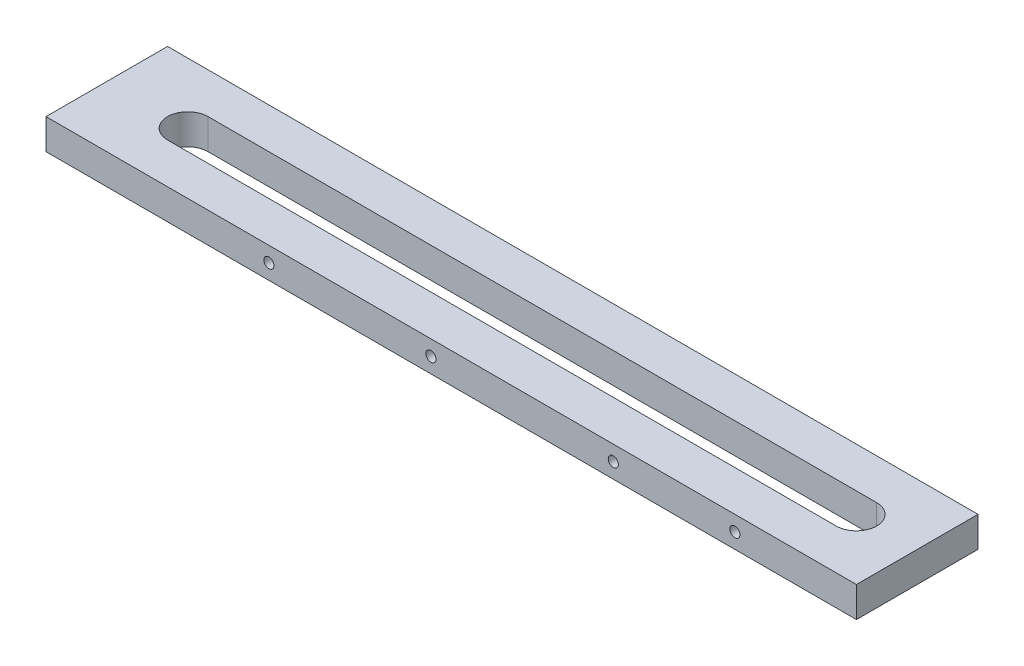
from build123d import *

# Parameters (mm, degrees)
SKETCH1_W           = 508
SKETCH1_H           = 76.2
BOSS_EXTRUDE1_DEPTH = 19.05
CUT_EXTRUDE1_DEPTH  = 20.05
SKETCH5_R           = 3.175
CUT_EXTRUDE3_DEPTH  = 12.7


with BuildPart() as part:
    # Sketch1 → Boss-Extrude1 (new body)
    with BuildSketch(Plane(origin=(0, 0, 0), x_dir=(1, 0, 0), z_dir=(0, 1, 0))):
        Rectangle(SKETCH1_W, SKETCH1_H)
    extrude(amount=BOSS_EXTRUDE1_DEPTH)

    # Sketch3 → Cut-Extrude1 (cut, through all)
    with BuildSketch(Plane(origin=(0, 19.05, 0), x_dir=(1, 0, 0), z_dir=(0, 1, 0))):
        with BuildLine():
            Line((-203.2, 12.7), (215.9, 12.7))
            ThreePointArc((215.9, 12.7), (228.6, 0), (215.9, -12.7))
            Line((215.9, -12.7), (-203.2, -12.7))
            ThreePointArc((-203.2, -12.7), (-215.9, 0), (-203.2, 12.7))
        make_face()
    extrude(amount=-CUT_EXTRUDE1_DEPTH, mode=Mode.SUBTRACT)

    # Sketch5 → Cut-Extrude3 (cut)
    with BuildSketch(Plane.XY.offset(38.1)):
        with Locations((-114.3, 9.525)):
            Circle(SKETCH5_R)
        with Locations((-12.7, 9.525)):
            Circle(SKETCH5_R)
        with Locations((101.6, 9.525)):
            Circle(SKETCH5_R)
        with Locations((177.8, 9.525)):
            Circle(SKETCH5_R)
    extrude(amount=-CUT_EXTRUDE3_DEPTH, mode=Mode.SUBTRACT)


solid = part.part
